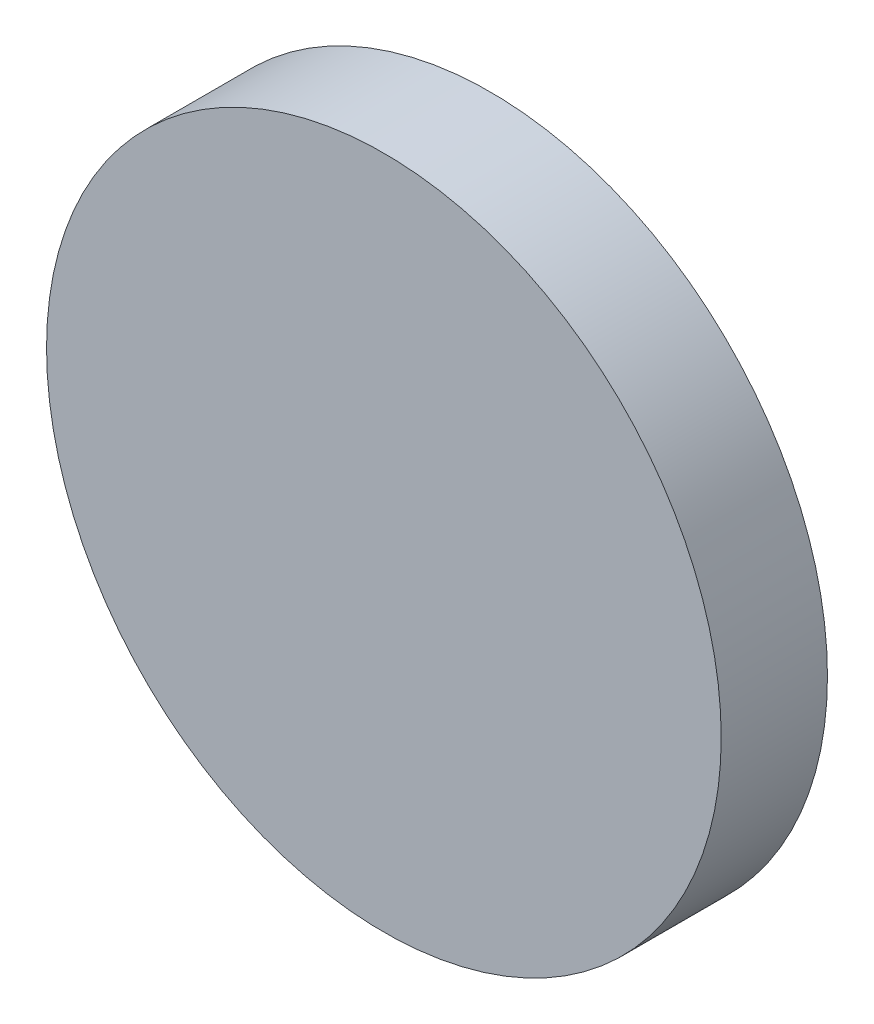
from build123d import *

# Parameters (mm, degrees)
SKETCH_1_R      = 6.35
EXTRUDE_1_DEPTH = 2


with BuildPart() as part:
    # 草图1 → 凸台-拉伸1 (new body)
    with BuildSketch(Plane.XY):
        Circle(SKETCH_1_R)
    extrude(amount=EXTRUDE_1_DEPTH)


solid = part.part
